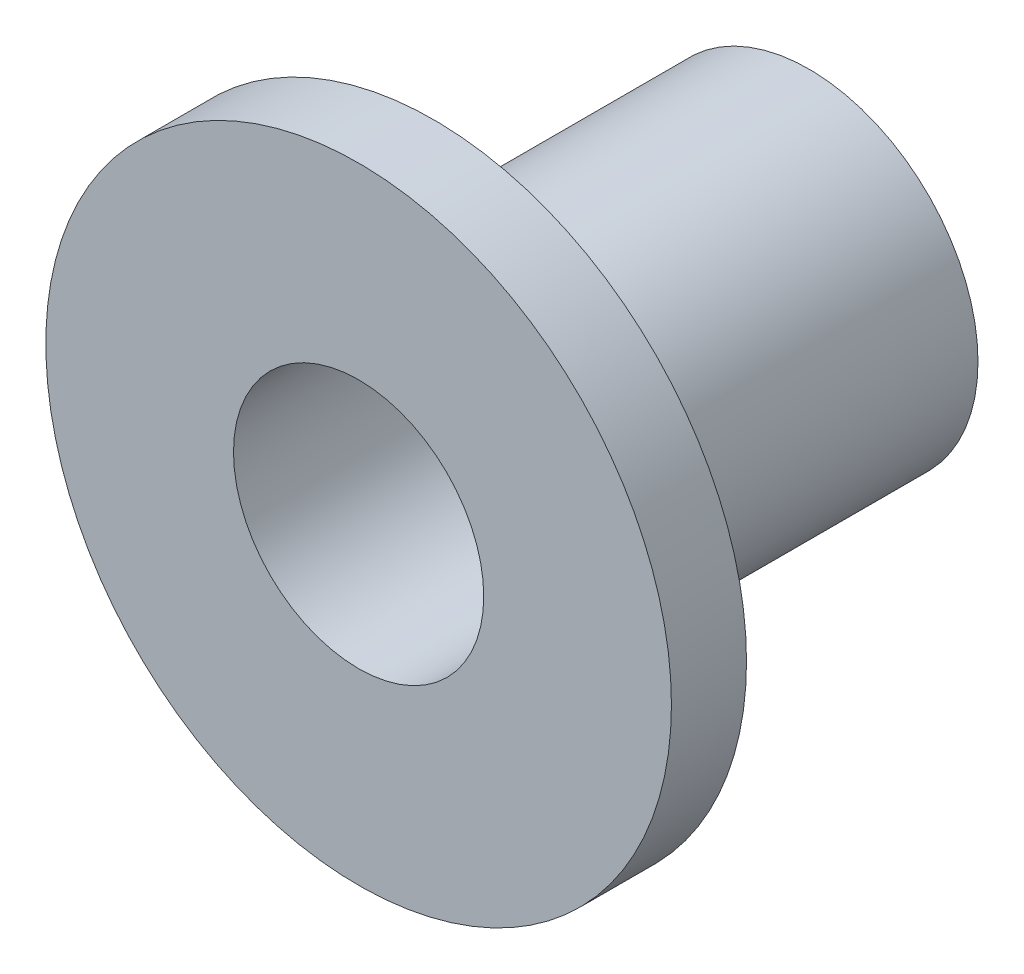
from build123d import *

# Parameters (mm, degrees)
SKETCH1_R           = 0.3375
BOSS_EXTRUDE1_DEPTH = 0.9
SKETCH2_R           = 0.625
BOSS_EXTRUDE2_DEPTH = 0.15
SKETCH3_R           = 0.25
CUT_EXTRUDE1_DEPTH  = 1.9


with BuildPart() as part:
    # Sketch1 → Boss-Extrude1 (new body)
    with BuildSketch(Plane.XY):
        Circle(SKETCH1_R)
    extrude(amount=-BOSS_EXTRUDE1_DEPTH)

    # Sketch2 → Boss-Extrude2 (add)
    with BuildSketch(Plane.XY):
        Circle(SKETCH2_R)
    extrude(amount=-BOSS_EXTRUDE2_DEPTH)

    # Sketch3 → Cut-Extrude1 (cut, through all)
    with BuildSketch(Plane.XY):
        Circle(SKETCH3_R)
    extrude(amount=-CUT_EXTRUDE1_DEPTH, mode=Mode.SUBTRACT)


solid = part.part
